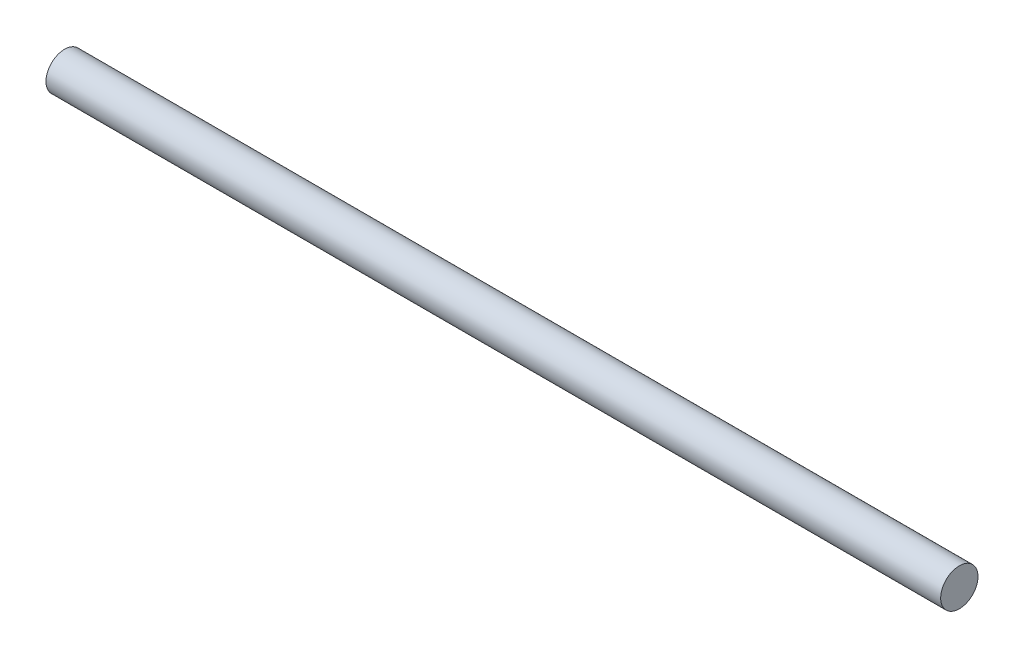
from build123d import *

# Parameters (mm, degrees)
SKETCH1_R           = 19.05
BOSS_EXTRUDE1_DEPTH = 456.55


with BuildPart() as part:
    # Sketch1 → Boss-Extrude1 (new body, symmetric)
    with BuildSketch(Plane(origin=(0, 0, 0), x_dir=(0, 0, -1), z_dir=(1, 0, 0))):
        Circle(SKETCH1_R)
    extrude(amount=BOSS_EXTRUDE1_DEPTH, both=True)


solid = part.part
